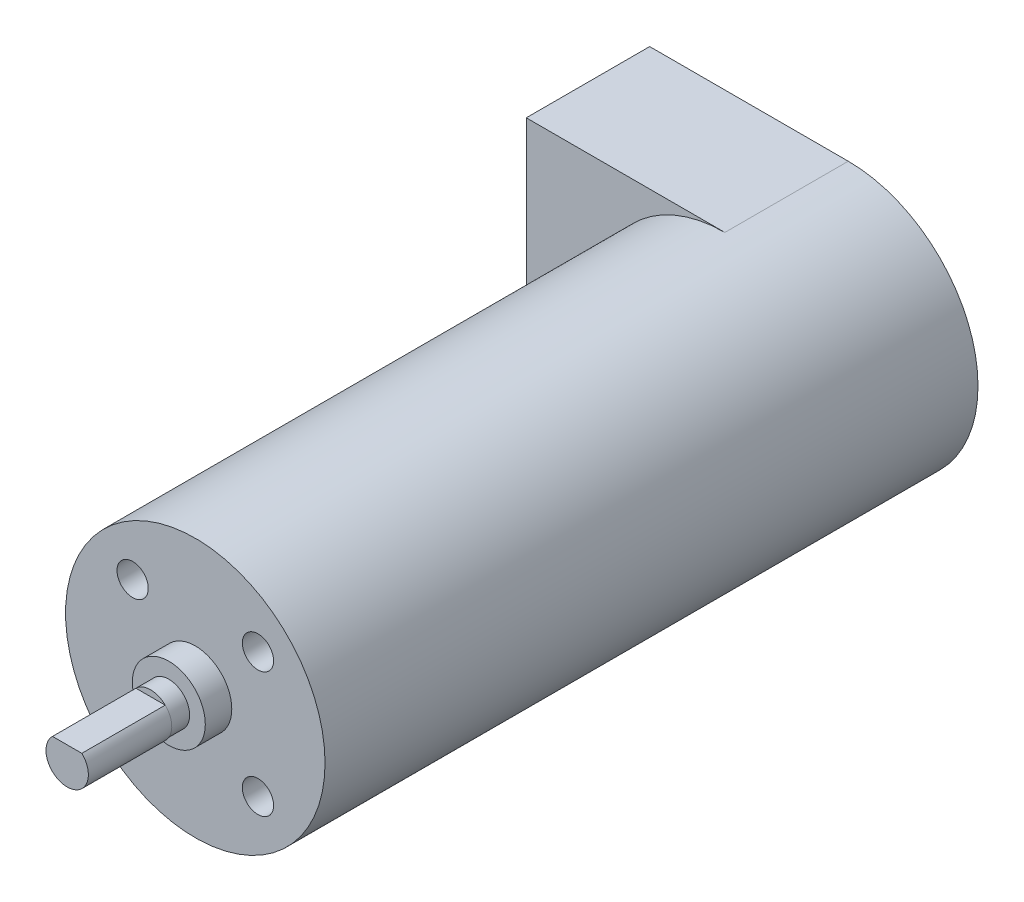
from build123d import *
from build123d.topology import SkipClean

# Parameters (mm, degrees)
BOSS_EXTRUDE1_DEPTH      = 25.4
BOSS_EXTRUDE1_DEPTH_BACK = 25.4
SKETCH1_R                = 12.446
SKETCH2_R                = 3.5
BOSS_EXTRUDE2_DEPTH      = 2.54
SKETCH4_R                = 2
BOSS_EXTRUDE3_DEPTH      = 1.75
BOSS_EXTRUDE4_DEPTH      = 8
SKETCH6_R                = 1.5
CUT_EXTRUDE1_DEPTH       = 3.175
BOSS_EXTRUDE5_DEPTH      = 11.8364


with BuildPart() as part:
    # Sketch1 → Boss-Extrude1 (new, two sides: drawn at the far end of the back side and taken through both)
    with BuildSketch(Plane.XY.offset(-BOSS_EXTRUDE1_DEPTH_BACK)):
        Circle(SKETCH1_R)
    extrude(amount=BOSS_EXTRUDE1_DEPTH + BOSS_EXTRUDE1_DEPTH_BACK)

    # Sketch2 → Boss-Extrude2 (add)
    with BuildSketch(Plane.XY.offset(25.4)):
        Circle(SKETCH2_R)
    extrude(amount=BOSS_EXTRUDE2_DEPTH)

    # Sketch4 → Boss-Extrude3 (add)
    with BuildSketch(Plane.XY.offset(27.94)):
        Circle(SKETCH4_R)
    extrude(amount=BOSS_EXTRUDE3_DEPTH)

    # Sketch5 → Boss-Extrude4 (add)
    with BuildSketch(Plane.XY.offset(29.69)):
        with BuildLine():
            Line((1.405616757, 1.422758424), (-1.405616757, 1.422758424))
            ThreePointArc((-1.405616757, 1.422758424), (0, -2.081119268), (1.405616757, 1.422758424))
        make_face()
    extrude(amount=BOSS_EXTRUDE4_DEPTH)

    # Sketch6 → Cut-Extrude1 (cut)
    with BuildSketch(Plane.XY.offset(25.4)):
        with Locations((6.01040764, 6.01040764)):
            Circle(SKETCH6_R)
        with Locations((6.01040764, -6.01040764)):
            Circle(SKETCH6_R)
        with Locations((-6.01040764, -6.01040764)):
            Circle(SKETCH6_R)
        with Locations((-6.01040764, 6.01040764)):
            Circle(SKETCH6_R)
    extrude(amount=-CUT_EXTRUDE1_DEPTH, mode=Mode.SUBTRACT)

    # Sketch7 → Boss-Extrude5 (add)
    with SkipClean():  # the faces are left unmerged after this step: merging them gives an invalid solid
        with BuildSketch(Plane(origin=(0, 0, -25.4), x_dir=(-1, 0, 0), z_dir=(0, 0, -1))):
            with BuildLine():
                Line((0, 12.446), (19.05, 12.446))
                Line((19.05, 12.446), (19.05, -12.446))
                Line((19.05, -12.446), (0, -12.446))
                ThreePointArc((0, -12.446), (-12.446, 0), (0, 12.446))
            make_face()
        extrude(amount=BOSS_EXTRUDE5_DEPTH)
    add(part.part.scale(1), mode=Mode.REPLACE)  # the faces are merged on a copy


solid = part.part
